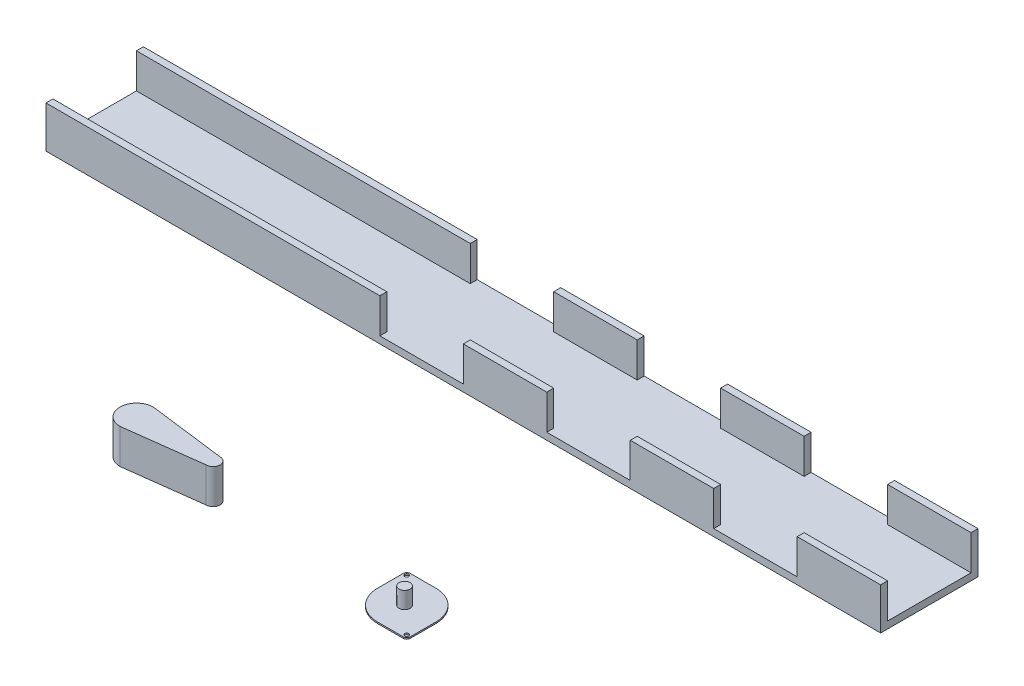
from build123d import *

# Parameters (mm, degrees)
SKETCH1_W           = 600
SKETCH1_H           = 70
BOSS_EXTRUDE1_DEPTH = 30
SKETCH3_W           = 60
SKETCH3_H           = 25
CUT_EXTRUDE2_DEPTH  = 600
SKETCH4_W           = 60
SKETCH4_H           = 25
CUT_EXTRUDE3_DEPTH  = 70
SKETCH10_W          = 60
SKETCH10_H          = 25
CUT_EXTRUDE5_DEPTH  = 70
BOSS_EXTRUDE4_DEPTH = 25
SKETCH13_R          = 1.5
BOSS_EXTRUDE5_DEPTH = 1
SKETCH14_R          = 4
BOSS_EXTRUDE6_DEPTH = 12


with BuildPart() as part:
    # Sketch1 → Boss-Extrude1 (new body)
    with BuildSketch(Plane(origin=(0, 0, 0), x_dir=(1, 0, 0), z_dir=(0, 1, 0))):
        Rectangle(SKETCH1_W, SKETCH1_H)
    extrude(amount=BOSS_EXTRUDE1_DEPTH)

    # Sketch3 → Cut-Extrude2 (cut)
    with BuildSketch(Plane.ZY.offset(300)):
        with Locations((0, 17.5)):
            Rectangle(SKETCH3_W, SKETCH3_H)
    extrude(amount=-CUT_EXTRUDE2_DEPTH, mode=Mode.SUBTRACT)

    # Sketch4 → Cut-Extrude3 (cut)
    with BuildSketch(Plane.XY.offset(35)):
        with Locations((210, 17.5)):
            Rectangle(SKETCH4_W, SKETCH4_H)
    extrude(amount=-CUT_EXTRUDE3_DEPTH, mode=Mode.SUBTRACT)

    # Sketch10 → Cut-Extrude5 (cut)
    with BuildSketch(Plane.XY.offset(35)):
        with Locations((90, 17.5)):
            Rectangle(SKETCH10_W, SKETCH10_H)
        with Locations((-30, 17.5)):
            Rectangle(SKETCH10_W, SKETCH10_H)
    extrude(amount=-CUT_EXTRUDE5_DEPTH, mode=Mode.SUBTRACT)


with BuildPart() as body_2:
    # Sketch11 → Boss-Extrude4 (new body)
    with BuildSketch(Plane(origin=(0, 0, 0), x_dir=(1, 0, 0), z_dir=(0, 1, 0))):
        with BuildLine():
            Line((-77.099833846, -180.746319388), (-22.099833846, -187.746319388))
            ThreePointArc((-22.099833846, -187.746319388), (-17.099833846, -192.746319388), (-22.099833846, -197.746319388))
            Line((-22.099833846, -197.746319388), (-77.099833846, -204.746319388))
            ThreePointArc((-77.099833846, -204.746319388), (-89.099833846, -192.746319388), (-77.099833846, -180.746319388))
        make_face()
    extrude(amount=BOSS_EXTRUDE4_DEPTH)


with BuildPart() as body_3:
    # Sketch13 → Boss-Extrude5 (new body)
    with BuildSketch(Plane(origin=(0, 0, 0), x_dir=(1, 0, 0), z_dir=(0, 1, 0))):
        with BuildLine():
            Line((94.761994393, -167.942193968), (113.27317523, -167.942193968))
            ThreePointArc((113.27317523, -167.942193968), (128.122417635, -174.092951563), (134.27317523, -188.942193968))
            Line((134.27317523, -188.942193968), (134.27317523, -207.453374805))
            ThreePointArc((134.27317523, -207.453374805), (133.544216975, -209.213235712), (131.784356068, -209.942193968))
            Line((131.784356068, -209.942193968), (113.27317523, -209.942193968))
            ThreePointArc((113.27317523, -209.942193968), (98.423932826, -203.791436372), (92.27317523, -188.942193968))
            Line((92.27317523, -188.942193968), (92.27317523, -170.43101313))
            ThreePointArc((92.27317523, -170.43101313), (93.002133486, -168.671152223), (94.761994393, -167.942193968))
        make_face()
        with Locations((94.761994393, -170.43101313)):
            Circle(SKETCH13_R, mode=Mode.SUBTRACT)
        with Locations((131.784356068, -207.453374805)):
            Circle(SKETCH13_R, mode=Mode.SUBTRACT)
    extrude(amount=BOSS_EXTRUDE5_DEPTH)

    # Sketch14 → Boss-Extrude6 (add)
    with BuildSketch(Plane(origin=(0, 1, 0), x_dir=(1, 0, 0), z_dir=(0, 1, 0))):
        with Locations((112.531105399, -189.756511726)):
            Circle(SKETCH14_R)
    extrude(amount=BOSS_EXTRUDE6_DEPTH)


solid = Compound([part.part, body_2.part, body_3.part])
